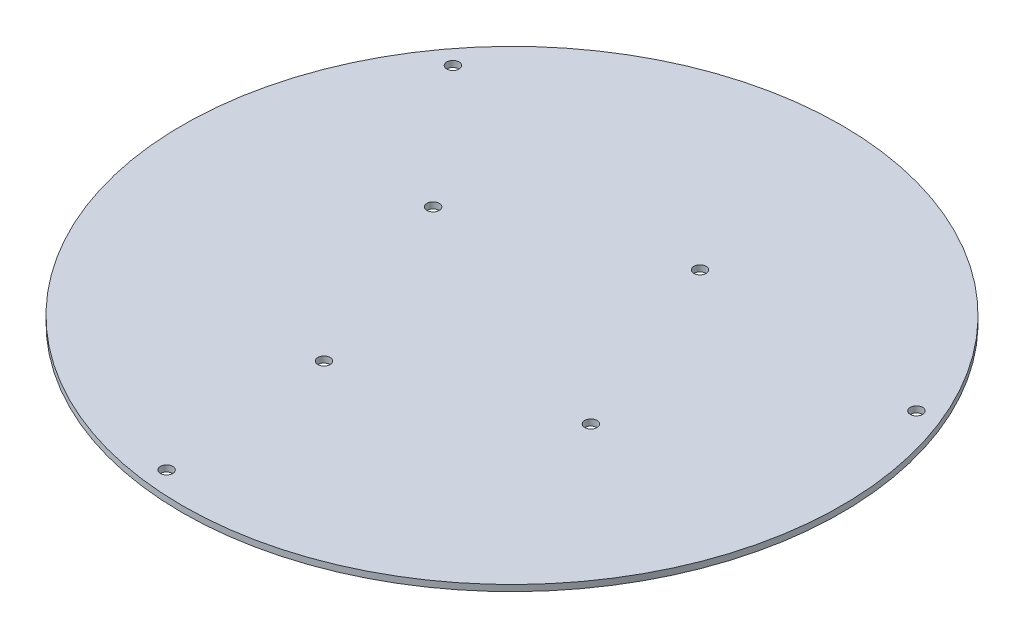
from build123d import *

# Parameters (mm, degrees)
CROQUIS1_R              = 160
CROQUIS1_R_2            = 3
SALIENTE_EXTRUIR2_DEPTH = 3


with BuildPart() as part:
    # Croquis1 → Saliente-Extruir2 (new body)
    with BuildSketch(Plane(origin=(0, 0, 0), x_dir=(1, 0, 0), z_dir=(0, 1, 0))):
        Circle(CROQUIS1_R)
        with Locations((138.31376779, 58.045685797)):
            Circle(CROQUIS1_R_2, mode=Mode.SUBTRACT)
        with Locations((-18.887845415, -148.806079498)):
            Circle(CROQUIS1_R_2, mode=Mode.SUBTRACT)
        with Locations((-64.794876894, 26.488184691)):
            Circle(CROQUIS1_R_2, mode=Mode.SUBTRACT)
        with Locations((26.488184691, 64.794876894)):
            Circle(CROQUIS1_R_2, mode=Mode.SUBTRACT)
        with Locations((64.794876894, -26.488184691)):
            Circle(CROQUIS1_R_2, mode=Mode.SUBTRACT)
        with Locations((-26.488184691, -64.794876894)):
            Circle(CROQUIS1_R_2, mode=Mode.SUBTRACT)
        with Locations((-119.425922375, 90.760393701)):
            Circle(CROQUIS1_R_2, mode=Mode.SUBTRACT)
    extrude(amount=SALIENTE_EXTRUIR2_DEPTH)


solid = part.part
